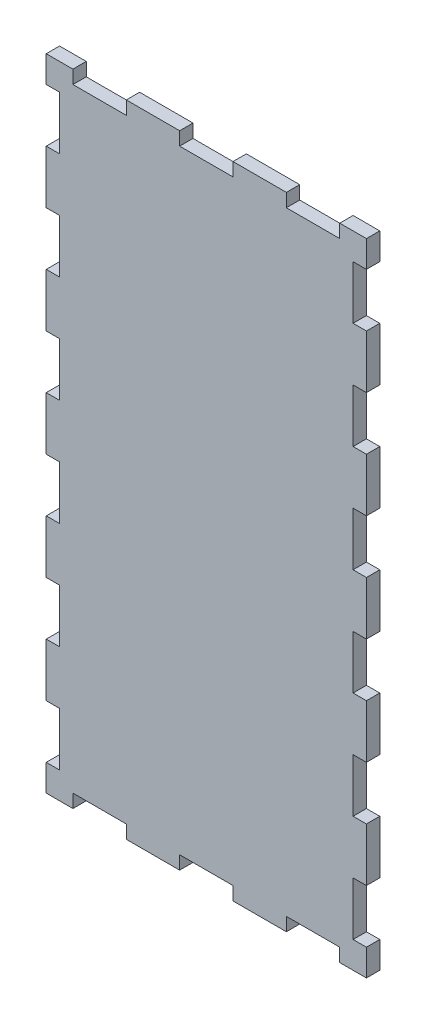
from build123d import *

# Parameters (mm, degrees)
SKETCH1_W            = 76.2
SKETCH1_H            = 152.4
EXTRUDE1_DEPTH       = 3.175
SKETCH3_W            = 3.175
SKETCH3_H            = 12.7
CUT_EXTRUDE1_DEPTH   = 3.175
LPATTERN1_COUNT      = 6
LPATTERN1_PITCH      = 25.4
LPATTERN1_COUNT_DIR2 = 2
LPATTERN1_PITCH_DIR2 = 73.025
SKETCH4_W            = 12.7
SKETCH4_H            = 3.175
CUT_EXTRUDE2_DEPTH   = 3.175
LPATTERN2_COUNT      = 3
LPATTERN2_PITCH      = 25.4
LPATTERN2_COUNT_DIR2 = 2
LPATTERN2_PITCH_DIR2 = 149.225


with BuildPart() as part:
    # Sketch1 → Extrude1 (new body)
    with BuildSketch(Plane.XY):
        with Locations((38.1, 76.2)):
            Rectangle(SKETCH1_W, SKETCH1_H)
    extrude(amount=EXTRUDE1_DEPTH)

    # Sketch3 → Cut-Extrude1 (cut)
    with BuildSketch(Plane.XY.offset(3.175)):
        with Locations((74.6125, 139.7)):
            Rectangle(SKETCH3_W, SKETCH3_H)
    cut_extrude1 = extrude(amount=-CUT_EXTRUDE1_DEPTH, mode=Mode.SUBTRACT)

    # LPattern1: Cut-Extrude1 6 × 2
    with Locations(*[(-j * LPATTERN1_PITCH_DIR2, -i * LPATTERN1_PITCH, 0) for i in range(LPATTERN1_COUNT) for j in range(LPATTERN1_COUNT_DIR2) if (i, j) != (0, 0)]):
        add(cut_extrude1, mode=Mode.SUBTRACT)

    # Sketch4 → Cut-Extrude2 (cut)
    with BuildSketch(Plane.XY.offset(3.175)):
        with Locations((63.5, 150.8125)):
            Rectangle(SKETCH4_W, SKETCH4_H)
    cut_extrude2 = extrude(amount=-CUT_EXTRUDE2_DEPTH, mode=Mode.SUBTRACT)

    # LPattern2: Cut-Extrude2 3 × 2
    with Locations(*[(-i * LPATTERN2_PITCH, -j * LPATTERN2_PITCH_DIR2, 0) for i in range(LPATTERN2_COUNT) for j in range(LPATTERN2_COUNT_DIR2) if (i, j) != (0, 0)]):
        add(cut_extrude2, mode=Mode.SUBTRACT)


solid = part.part
